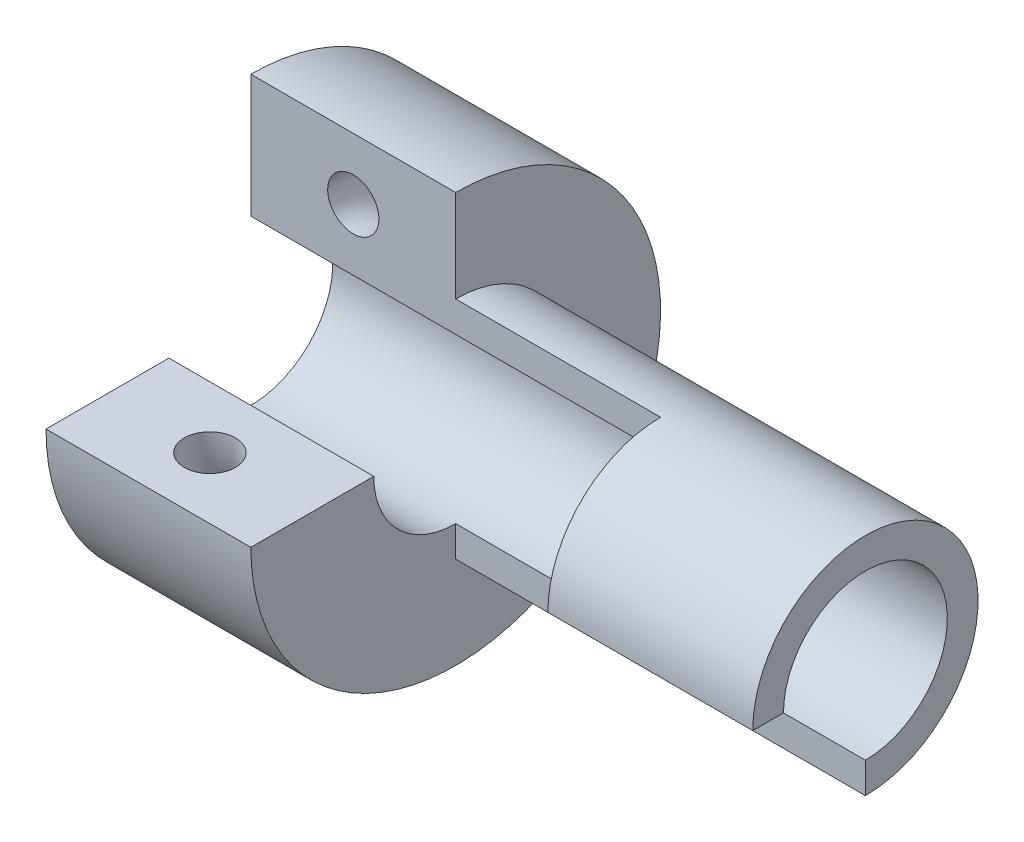
from build123d import *
from build123d.topology import SkipClean

# Parameters (mm, degrees)
SKETCH1_W           = 20
SKETCH1_H           = 12
REVOLVE2_ANGLE      = 270
SKETCH4_R           = 2.5
CUT_REVOLVE1_ANGLE  = 270
BOSS_EXTRUDE3_DEPTH = 40
SKETCH10_W          = 20
SKETCH10_H          = 3
REVOLVE4_ANGLE      = 90


with BuildPart() as part:
    # Sketch1 → Revolve2 (revolve)
    with BuildSketch(Plane(origin=(0, 0, 0), x_dir=(1, 0, 0), z_dir=(0, 1, 0))):
        with Locations((10, 6)):
            Rectangle(SKETCH1_W, SKETCH1_H)
    revolve(axis=Axis((0, 0, -20), (1, 0, 0)), revolution_arc=REVOLVE2_ANGLE)

    # Sketch4 → Cut-Revolve1 (revolve, cut)
    with BuildSketch(Plane(origin=(0, 0, 0), x_dir=(1, 0, 0), z_dir=(0, 1, 0))):
        with Locations((10, 6)):
            Circle(SKETCH4_R)
    revolve(axis=Axis((20, 0, -20), (1, 0, 0)), revolution_arc=CUT_REVOLVE1_ANGLE, mode=Mode.SUBTRACT)

    # Sketch9 → Boss-Extrude3 (add)
    with BuildSketch(Plane(origin=(20, 0, 0), x_dir=(0, 0, -1), z_dir=(1, 0, 0))):
        with BuildLine():
            Line((20, -11), (20, -8))
            ThreePointArc((20, -8), (28, 0), (20, 8))
            Line((20, 8), (20, 11))
            ThreePointArc((20, 11), (31, 0), (20, -11))
        make_face()
    extrude(amount=BOSS_EXTRUDE3_DEPTH)

    # Sketch10 → Revolve4 (revolve)
    with SkipClean():  # the faces are left unmerged after this step: merging them gives an invalid solid
        with BuildSketch(Plane.XY.offset(-20)):
            with Locations((50, 9.5)):
                Rectangle(SKETCH10_W, SKETCH10_H)
        revolve(axis=Axis((20, 0, -20), (1, 0, 0)), revolution_arc=REVOLVE4_ANGLE)


solid = part.part
